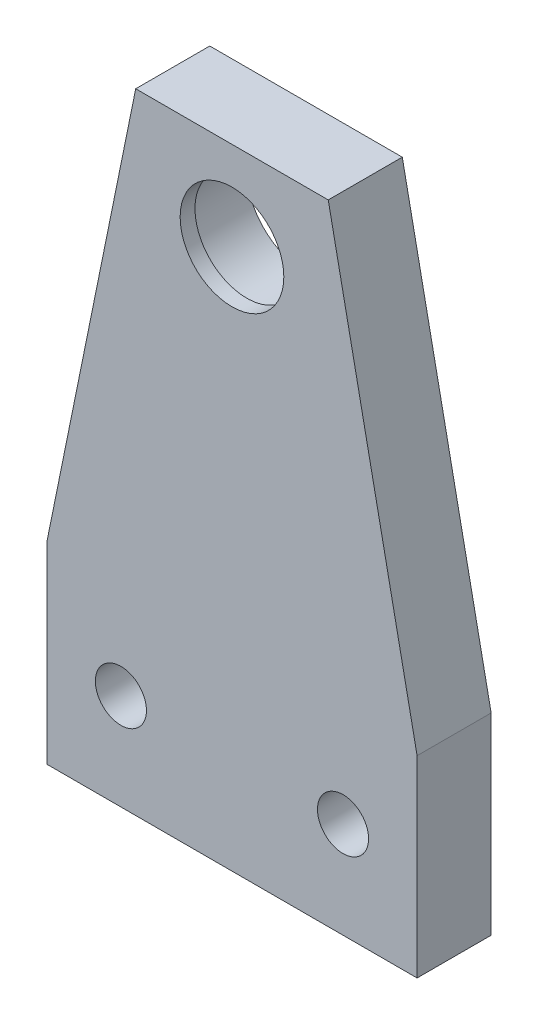
from build123d import *

# Parameters (mm, degrees)
SKETCH_1_R          = 7
SKETCH_1_R_2        = 3.45
EXTRUDE_1_DEPTH     = 10
SKETCH_2_R          = 8.05
SKETCH_2_R_2        = 4
CUT_EXTRUDE_1_DEPTH = 8


with BuildPart() as part:
    # 草图1 → 凸台-拉伸1 (new body)
    with BuildSketch(Plane.XY):
        Polygon((-25, 0), (25, 0), (25, 26), (13, 85), (-13, 85), (-25, 26), align=None)
        with Locations((0, 73)):
            Circle(SKETCH_1_R, mode=Mode.SUBTRACT)
        with Locations((-15, 13)):
            Circle(SKETCH_1_R_2, mode=Mode.SUBTRACT)
        with Locations((15, 13)):
            Circle(SKETCH_1_R_2, mode=Mode.SUBTRACT)
    extrude(amount=EXTRUDE_1_DEPTH)

    # 草图2 → 切除-拉伸1 (cut)
    with BuildSketch(Plane(origin=(0, 0, 0), x_dir=(-1, 0, 0), z_dir=(0, 0, -1))):
        with Locations((0, 73)):
            Circle(SKETCH_2_R)
        with Locations((0, 73)):
            Circle(SKETCH_2_R_2, mode=Mode.SUBTRACT)
    extrude(amount=-CUT_EXTRUDE_1_DEPTH, mode=Mode.SUBTRACT)


solid = part.part
